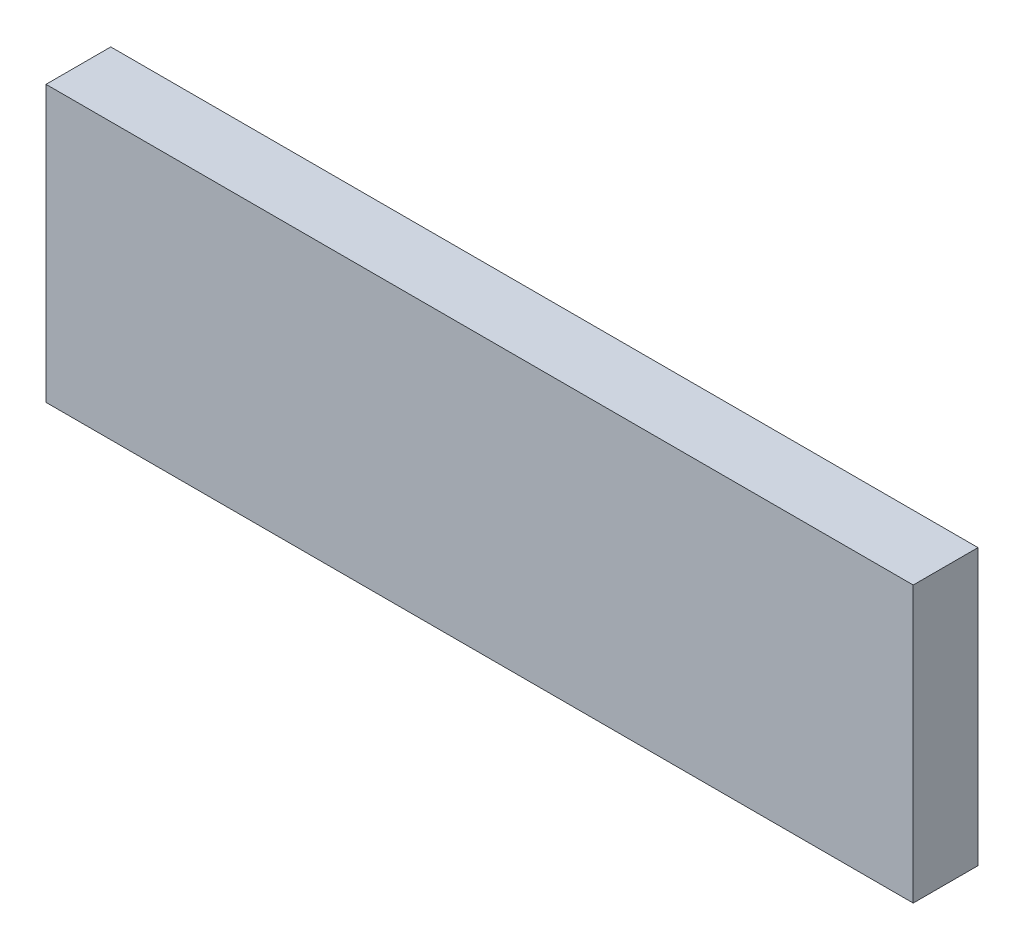
from build123d import *

# Parameters (mm, degrees)
SKETCH1_W           = 340
SKETCH1_H           = 108
BOSS_EXTRUDE1_DEPTH = 25.4


with BuildPart() as part:
    # Sketch1 → Boss-Extrude1 (new body)
    with BuildSketch(Plane.XY):
        with Locations((170, 54)):
            Rectangle(SKETCH1_W, SKETCH1_H)
    extrude(amount=BOSS_EXTRUDE1_DEPTH)


solid = part.part
